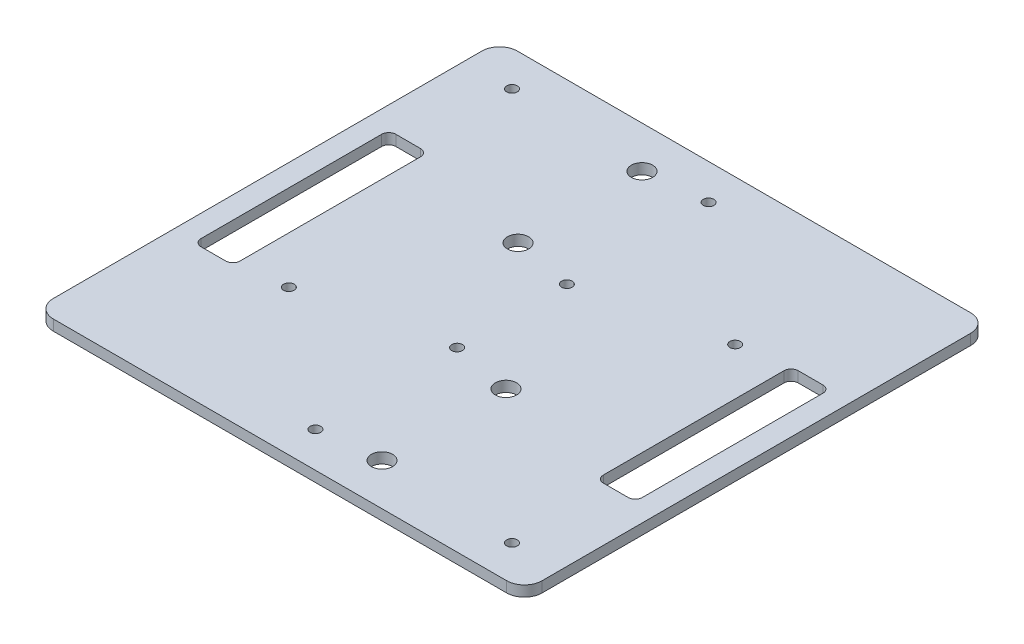
from build123d import *

# Parameters (mm, degrees)
SKETCH1_W                = 138
SKETCH1_H                = 131
BOSS_EXTRUDE1_DEPTH      = 3
SKETCH2_R                = 3
SKETCH2_R_2              = 1.5
SKETCH2_W                = 11
SKETCH2_H                = 55
CUT_EXTRUDE1_DEPTH       = 96.185345511
FILLET1_R                = 5
FILLET2_R                = 2
CIRPATTERN1_COUNT        = 2
FILLET2_OF_CIRPATTERN1_R = 2


with BuildPart() as part:
    # Sketch1 → Boss-Extrude1 (new body)
    with BuildSketch(Plane(origin=(0, 0, 0), x_dir=(1, 0, 0), z_dir=(0, 1, 0))):
        Rectangle(SKETCH1_W, SKETCH1_H)
    extrude(amount=BOSS_EXTRUDE1_DEPTH)

    # Sketch2 → Cut-Extrude1 (cut, through all)
    with BuildSketch(Plane(origin=(0, 3, 0), x_dir=(1, 0, 0), z_dir=(0, 1, 0))):
        with Locations((-17, 18.7)):
            Circle(SKETCH2_R)
        with Locations((-17, 53.7)):
            Circle(SKETCH2_R)
        with Locations((0, 55.5)):
            Circle(SKETCH2_R_2)
        with Locations((0, 15.5)):
            Circle(SKETCH2_R_2)
        with Locations((-55.5, 55.5)):
            Circle(SKETCH2_R_2)
        with Locations((-38.5, -24.5)):
            Circle(SKETCH2_R_2)
        with Locations((-57.3, 0.5)):
            Rectangle(SKETCH2_W, SKETCH2_H)
    cut_extrude1 = extrude(amount=-CUT_EXTRUDE1_DEPTH, mode=Mode.SUBTRACT)

    # Fillet1
    fillet1_edges = [part.edges().sort_by_distance(p)[0] for p in [
        (-69, 1.5, -65.5),
        (69, 1.5, -65.5),
        (69, 1.5, 65.5),
        (-69, 1.5, 65.5),
    ]]
    fillet(fillet1_edges, radius=FILLET1_R)

    # Fillet2
    fillet2_edges = [part.edges().sort_by_distance(p)[0] for p in [
        (-62.8, 1.5, -28),
        (-51.8, 1.5, -28),
        (-51.8, 1.5, 27),
        (-62.8, 1.5, 27),
    ]]
    fillet(fillet2_edges, radius=FILLET2_R)

    # CirPattern1: Cut-Extrude1 ×2 about axis
    cirpattern1_axis = Axis((0, -0.15, 0), (0, 1, 0))
    for i in range(1, CIRPATTERN1_COUNT):
        add(cut_extrude1.rotate(cirpattern1_axis, i * 360 / CIRPATTERN1_COUNT), mode=Mode.SUBTRACT)

    # Fillet2 of CirPattern1
    fillet2_of_cirpattern1_edges = [part.edges().sort_by_distance(p)[0] for p in [
        (62.8, 1.5, 28),
        (51.8, 1.5, 28),
        (51.8, 1.5, -27),
        (62.8, 1.5, -27),
    ]]
    fillet(fillet2_of_cirpattern1_edges, radius=FILLET2_OF_CIRPATTERN1_R)


solid = part.part
